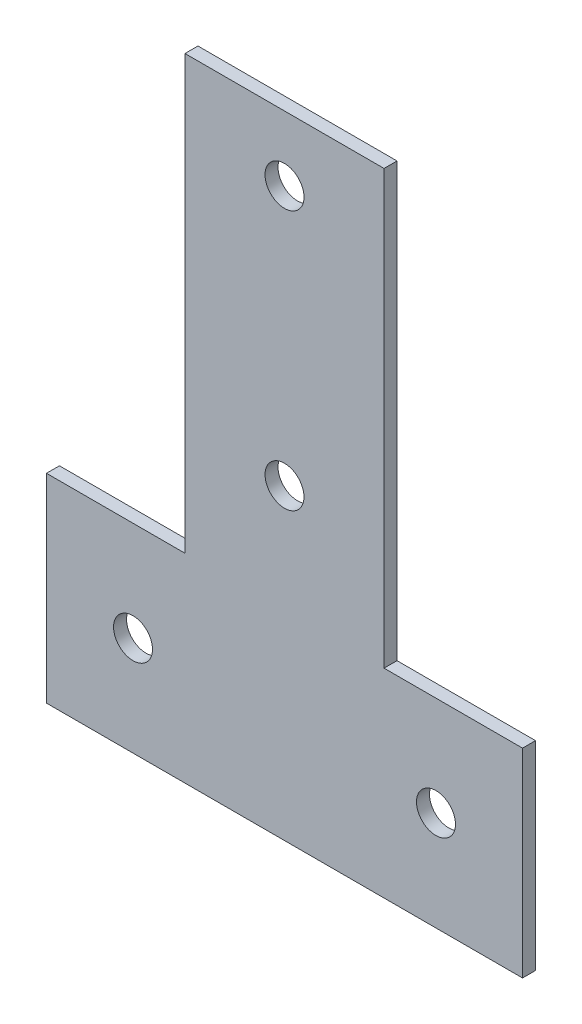
from build123d import *

# Parameters (mm, degrees)
SKETCH_1_R      = 4.5
EXTRUDE_1_DEPTH = 3


with BuildPart() as part:
    # Эскиз1 → Бобышка-Вытянуть1 (new body)
    with BuildSketch(Plane.XY):
        Polygon((-55, 0), (55, 0), (55, 46), (23, 46), (23, 146), (-23, 146), (-23, 46), (-55, 46), align=None)
        with Locations((0, 131)):
            Circle(SKETCH_1_R, mode=Mode.SUBTRACT)
        with Locations((0, 71)):
            Circle(SKETCH_1_R, mode=Mode.SUBTRACT)
        with Locations((-35, 23)):
            Circle(SKETCH_1_R, mode=Mode.SUBTRACT)
        with Locations((35, 23)):
            Circle(SKETCH_1_R, mode=Mode.SUBTRACT)
    extrude(amount=EXTRUDE_1_DEPTH)


solid = part.part
